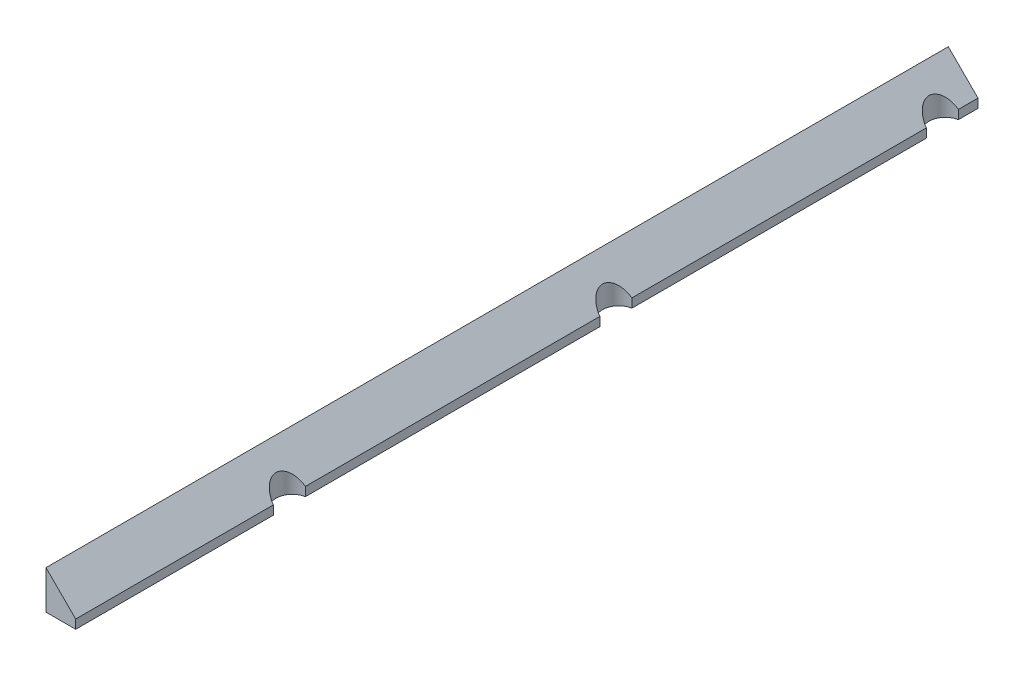
from build123d import *

# Parameters (mm, degrees)
BOSS_EXTRUDE1_DEPTH = 36.4
CUT_EXTRUDE1_REACH  = 4.6
SKETCH2_R           = 1.1
CUT_EXTRUDE3_START  = -2.6
SKETCH4_W           = 2
SKETCH4_H           = 12
CUT_EXTRUDE3_DEPTH  = 2.6


with BuildPart() as part:
    # Sketch1 → Boss-Extrude1 (new body, symmetric)
    with BuildSketch(Plane.XY):
        Polygon((0, 2.6), (0, 0), (2, 0), (2, 0.6), align=None)
    extrude(amount=BOSS_EXTRUDE1_DEPTH, both=True)

    # Cut-Extrude1: up to this face of the body (flat: up to its plane)
    cut_extrude1_end = Plane(part.part.faces().sort_by_distance((1, 1.6, 0))[0])
    # Sketch2 → Cut-Extrude1 (cut, up to the picked face)
    with BuildSketch(Plane.XZ, mode=Mode.PRIVATE) as cut_extrude1_sk1:
        with Locations((2.2, 0)):
            Circle(SKETCH2_R)
    cut_extrude1_tool1 = split(extrude(cut_extrude1_sk1.sketch, amount=-CUT_EXTRUDE1_REACH, mode=Mode.PRIVATE), bisect_by=cut_extrude1_end, keep=Keep.BOTH, mode=Mode.PRIVATE)
    add(cut_extrude1_tool1.solids().sort_by_distance((2.2, 0, 0))[0], mode=Mode.SUBTRACT)
    # Sketch2 → Cut-Extrude1 (cut, up to the picked face)
    with BuildSketch(Plane.XZ, mode=Mode.PRIVATE) as cut_extrude1_sk2:
        with Locations((2.2, 22)):
            Circle(SKETCH2_R)
    cut_extrude1_tool2 = split(extrude(cut_extrude1_sk2.sketch, amount=-CUT_EXTRUDE1_REACH, mode=Mode.PRIVATE), bisect_by=cut_extrude1_end, keep=Keep.BOTH, mode=Mode.PRIVATE)
    add(cut_extrude1_tool2.solids().sort_by_distance((2.2, 0, 22))[0], mode=Mode.SUBTRACT)
    # Sketch2 → Cut-Extrude1 (cut, up to the picked face)
    with BuildSketch(Plane.XZ, mode=Mode.PRIVATE) as cut_extrude1_sk3:
        with Locations((2.2, -22)):
            Circle(SKETCH2_R)
    cut_extrude1_tool3 = split(extrude(cut_extrude1_sk3.sketch, amount=-CUT_EXTRUDE1_REACH, mode=Mode.PRIVATE), bisect_by=cut_extrude1_end, keep=Keep.BOTH, mode=Mode.PRIVATE)
    add(cut_extrude1_tool3.solids().sort_by_distance((2.2, 0, -22))[0], mode=Mode.SUBTRACT)

    # Sketch4 → Cut-Extrude3 (cut)
    with BuildSketch(Plane(origin=(0, 0, 0), x_dir=(-1, 0, 0), z_dir=(0, -1, 0)).offset(CUT_EXTRUDE3_START)):
        with Locations((-1, 30.4)):
            Rectangle(SKETCH4_W, SKETCH4_H)
    extrude(amount=CUT_EXTRUDE3_DEPTH, mode=Mode.SUBTRACT)


solid = part.part
